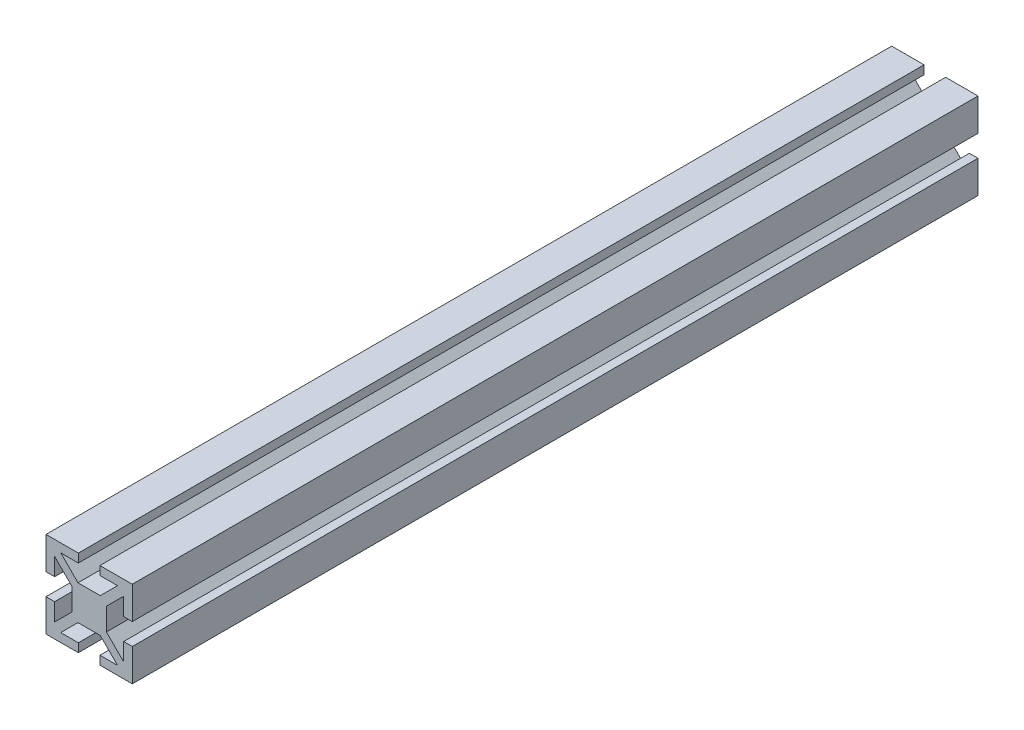
from build123d import *

# Parameters (mm, degrees)
BOSS_EXTRUDE1_DEPTH = 98
SKETCH2_R           = 2.5
CUT_EXTRUDE1_DEPTH  = 8


with BuildPart() as part:
    # Sketch1 → Boss-Extrude1 (new body, symmetric)
    with BuildSketch(Plane.XY):
        Polygon((-2.585786438, 4), (2.585786438, 4), (6.585786438, 8), (2.5, 8), (2.5, 10), (10, 10), (10, 2.5), (8, 2.5), (8, 6.585786438), (4, 2.585786438), (4, -2.585786438), (8, -6.585786438), (8, -2.5), (10, -2.5), (10, -10), (2.5, -10), (2.5, -8), (6.585786438, -8), (2.585786438, -4), (-2.585786438, -4), (-6.585786438, -8), (-2.5, -8), (-2.5, -10), (-10, -10), (-10, -2.5), (-8, -2.5), (-8, -6.585786438), (-4, -2.585786438), (-4, 2.585786438), (-8, 6.585786438), (-8, 2.5), (-10, 2.5), (-10, 10), (-2.5, 10), (-2.5, 8), (-6.585786438, 8), align=None)
    extrude(amount=BOSS_EXTRUDE1_DEPTH, both=True)

    # Sketch2 → Cut-Extrude1 (cut)
    with BuildSketch(Plane(origin=(4, 0, 0), x_dir=(0, 0, -1), z_dir=(1, 0, 0))):
        with Locations((88, 0)):
            Circle(SKETCH2_R)
        with Locations((-88, 0)):
            Circle(SKETCH2_R)
    extrude(amount=-CUT_EXTRUDE1_DEPTH, mode=Mode.SUBTRACT)


solid = part.part
